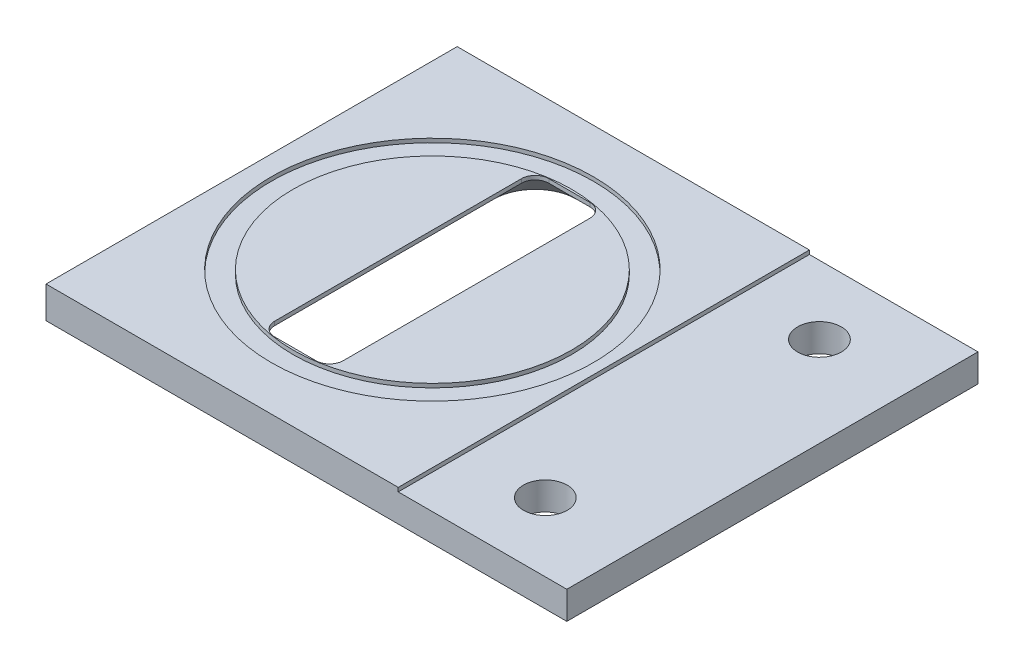
from build123d import *

# Parameters (mm, degrees)
SKETCH2_W           = 38
SKETCH2_H           = 30
BOSS_EXTRUDE1_DEPTH = 2.032
CUT_EXTRUDE4_DEPTH  = 3.032
CUT_EXTRUDE4_TAPER  = -45
SKETCH5_R           = 1.595
CUT_EXTRUDE5_DEPTH  = 3.0320001
SKETCH6_W           = 25.7
SKETCH6_H           = 30
SKETCH6_R           = 11.75
SKETCH6_R_2         = 10.1625
BOSS_EXTRUDE4_DEPTH = 0.2874


with BuildPart() as part:
    # Sketch2 → Boss-Extrude1 (new body)
    with BuildSketch(Plane(origin=(0, 0, 0), x_dir=(1, 0, 0), z_dir=(0, 1, 0))):
        with Locations((5.811028754, 0)):
            Rectangle(SKETCH2_W, SKETCH2_H)
    extrude(amount=BOSS_EXTRUDE1_DEPTH)

    # Sketch4 → Cut-Extrude4 (cut, through all)
    with BuildSketch(Plane(origin=(0, 2.032, 0), x_dir=(1, 0, 0), z_dir=(0, 1, 0))):
        with BuildLine():
            ThreePointArc((1.5, -10), (2.207106781, -9.707106781), (2.5, -9))
            Line((2.5, -9), (2.5, 9))
            ThreePointArc((2.5, 9), (2.207106781, 9.707106781), (1.5, 10))
            Line((1.5, 10), (-1.5, 10))
            ThreePointArc((-1.5, 10), (-2.207106781, 9.707106781), (-2.5, 9))
            Line((-2.5, 9), (-2.5, -9))
            ThreePointArc((-2.5, -9), (-2.207106781, -9.707106781), (-1.5, -10))
            Line((-1.5, -10), (1.5, -10))
        make_face()
    extrude(amount=-CUT_EXTRUDE4_DEPTH, taper=CUT_EXTRUDE4_TAPER, mode=Mode.SUBTRACT)

    # Sketch5 → Cut-Extrude5 (cut, through all)
    with BuildSketch(Plane(origin=(0, 2.032, 0), x_dir=(1, 0, 0), z_dir=(0, 1, 0))):
        with Locations((18.242707696, -10)):
            Circle(SKETCH5_R)
        with Locations((18.242707696, 10)):
            Circle(SKETCH5_R)
    extrude(amount=-CUT_EXTRUDE5_DEPTH, mode=Mode.SUBTRACT)

    # Sketch6 → Boss-Extrude4 (add)
    with BuildSketch(Plane(origin=(0, 2.032, 0), x_dir=(1, 0, 0), z_dir=(0, 1, 0))):
        with Locations((-0.338971246, 0)):
            Rectangle(SKETCH6_W, SKETCH6_H)
        Circle(SKETCH6_R, mode=Mode.SUBTRACT)
        Circle(SKETCH6_R_2)
        with BuildLine():
            Line((1.5, -10), (-1.5, -10))
            ThreePointArc((-1.5, -10), (-2.207106781, -9.707106781), (-2.5, -9))
            Line((-2.5, -9), (-2.5, 9))
            ThreePointArc((-2.5, 9), (-2.207106781, 9.707106781), (-1.5, 10))
            Line((-1.5, 10), (1.5, 10))
            ThreePointArc((1.5, 10), (2.207106781, 9.707106781), (2.5, 9))
            Line((2.5, 9), (2.5, -9))
            ThreePointArc((2.5, -9), (2.207106781, -9.707106781), (1.5, -10))
        make_face(mode=Mode.SUBTRACT)
    extrude(amount=BOSS_EXTRUDE4_DEPTH)


solid = part.part
